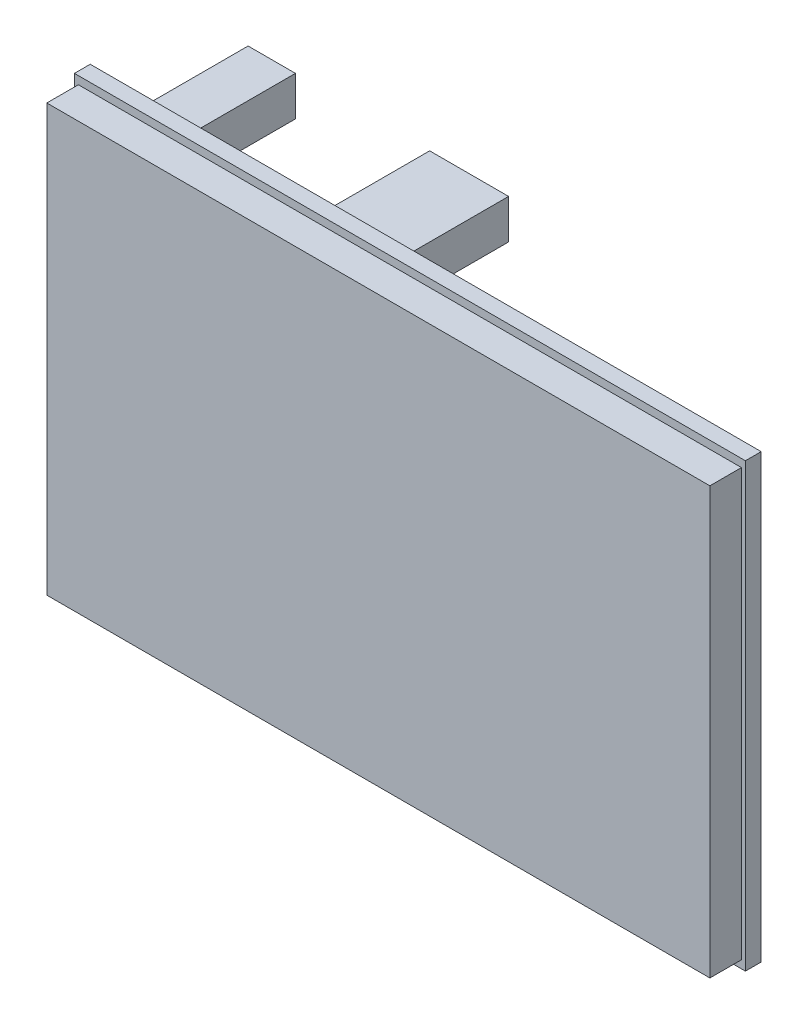
from build123d import *

# Parameters (mm, degrees)
ESQUISSE1_W        = 85
ESQUISSE1_H        = 56
BOSS_EXTRU_1_DEPTH = 2
ESQUISSE2_W        = 84
ESQUISSE2_H        = 54
BOSS_EXTRU_2_DEPTH = 4
ESQUISSE3_W        = 6
ESQUISSE3_H        = 5
ESQUISSE3_W_2      = 10
BOSS_EXTRU_3_DEPTH = 13
ESQUISSE4_W        = 15
ESQUISSE4_H        = 11
BOSS_EXTRU_4_DEPTH = 7
COQUE1_T           = -0.5
ESQUISSE5_W        = 7
ESQUISSE5_H        = 5
BOSS_EXTRU_5_DEPTH = 3
COQUE2_T           = -0.2
ESQUISSE6_W        = 7
ESQUISSE6_H        = 12
BOSS_EXTRU_6_DEPTH = 4
ESQUISSE7_R        = 2
BOSS_EXTRU_7_DEPTH = 3


with BuildPart() as part:
    # Esquisse1 → Boss.-Extru.1 (new body)
    with BuildSketch(Plane.XY):
        Rectangle(ESQUISSE1_W, ESQUISSE1_H)
    extrude(amount=BOSS_EXTRU_1_DEPTH)

    # Esquisse2 → Boss.-Extru.2 (add)
    with BuildSketch(Plane.XY.offset(2)):
        Rectangle(ESQUISSE2_W, ESQUISSE2_H)
    extrude(amount=BOSS_EXTRU_2_DEPTH)

    # Esquisse3 → Boss.-Extru.3 (add)
    with BuildSketch(Plane(origin=(0, 0, 0), x_dir=(-1, 0, 0), z_dir=(0, 0, -1))):
        with Locations((32.5, 24.5)):
            Rectangle(ESQUISSE3_W, ESQUISSE3_H)
        with Locations((7.5, 24.5)):
            Rectangle(ESQUISSE3_W_2, ESQUISSE3_H)
    extrude(amount=BOSS_EXTRU_3_DEPTH)

    # Esquisse4 → Boss.-Extru.4 (add)
    with BuildSketch(Plane(origin=(0, 0, 0), x_dir=(-1, 0, 0), z_dir=(0, 0, -1))):
        with Locations((11, -24.5)):
            Rectangle(ESQUISSE4_W, ESQUISSE4_H)
    extrude(amount=BOSS_EXTRU_4_DEPTH)

    # Coque1
    coque1_openings = [part.faces().sort_by_distance(p)[0] for p in [
        (-11, -30, -3.5),
    ]]
    offset(amount=COQUE1_T, openings=coque1_openings, kind=Kind.INTERSECTION)

    # Esquisse5 → Boss.-Extru.5 (add)
    with BuildSketch(Plane(origin=(0, 0, 0), x_dir=(-1, 0, 0), z_dir=(0, 0, -1))):
        with Locations((32, -26.5)):
            Rectangle(ESQUISSE5_W, ESQUISSE5_H)
    extrude(amount=BOSS_EXTRU_5_DEPTH)

    # Coque2
    coque2_openings = [part.faces().sort_by_distance(p)[0] for p in [
        (-32, -29, -1.5),
    ]]
    offset(amount=COQUE2_T, openings=coque2_openings, kind=Kind.INTERSECTION)

    # Esquisse6 → Boss.-Extru.6 (add)
    with BuildSketch(Plane(origin=(0, 0, 0), x_dir=(-1, 0, 0), z_dir=(0, 0, -1))):
        with Locations((-10, -22)):
            Rectangle(ESQUISSE6_W, ESQUISSE6_H)
    extrude(amount=BOSS_EXTRU_6_DEPTH)

    # Esquisse7 → Boss.-Extru.7 (add)
    with BuildSketch(Plane.XZ.offset(28)):
        with Locations((10, -2)):
            Circle(ESQUISSE7_R)
    extrude(amount=BOSS_EXTRU_7_DEPTH)


solid = part.part
